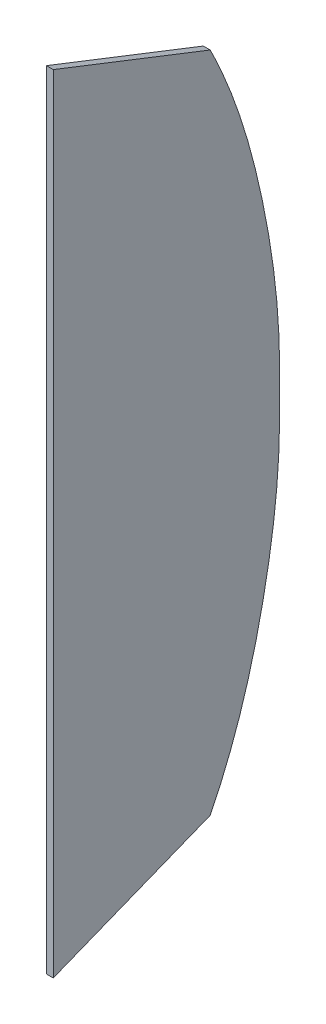
from build123d import *

# Parameters (mm, degrees)
EXTRUDE_2_DEPTH = 9


with BuildPart() as part:
    # Эскиз1 → Бобышка-Вытянуть2 (new body)
    with BuildSketch(Plane(origin=(0, 0, 0), x_dir=(0, 0, -1), z_dir=(1, 0, 0))):
        with BuildLine():
            Line((-455, -516.542644104), (-455, 516.556548518))
            Line((-455, 516.556548518), (-248.999999692, 435.905604479))
            add(Edge.make_bspline(
                [(-248.999999692, 435.905604479), (-244.812182794, 427.580683135), (-236.801363167, 410.73826292), (-222.212406758, 376.463926678), (-206.472110198, 332.573595341), (-191.065214882, 278.622516157), (-178.618404528, 223.741954043), (-168.601235151, 168.376182512), (-162.664180548, 121.995794186), (-159.588454358, 84.78039118), (-158.191016915, 56.847307797), (-157.699086883, 28.820440013), (-157.668208508, 0.657149051), (-157.69908686, -27.506141911), (-158.191016904, -55.533009684), (-159.588454431, -83.466093036), (-162.664180797, -120.681496001), (-168.601235656, -167.061884287), (-178.618405136, -222.427655869), (-191.065215126, -277.308218149), (-206.47210996, -331.259297463), (-222.212406313, -375.149628797), (-236.801362845, -409.423964908), (-244.812182664, -426.266385019), (-248.999999692, -434.591306286)],
                knots=[0.002534483, 0.002534483, 0.002534483, 0.002534483, 0.033626078, 0.064717673, 0.126900862, 0.189084052, 0.251267242, 0.313450431, 0.375633621, 0.406725216, 0.43781681, 0.468908405, 0.5, 0.531091595, 0.56218319, 0.593274784, 0.624366379, 0.686549569, 0.748732758, 0.810915948, 0.873099138, 0.935282327, 0.966373922, 0.997465517, 0.997465517, 0.997465517, 0.997465517], degree=3))
            Line((-248.999999692, -434.591306286), (-455, -516.542644104))
        make_face()
    extrude(amount=EXTRUDE_2_DEPTH)


solid = part.part
